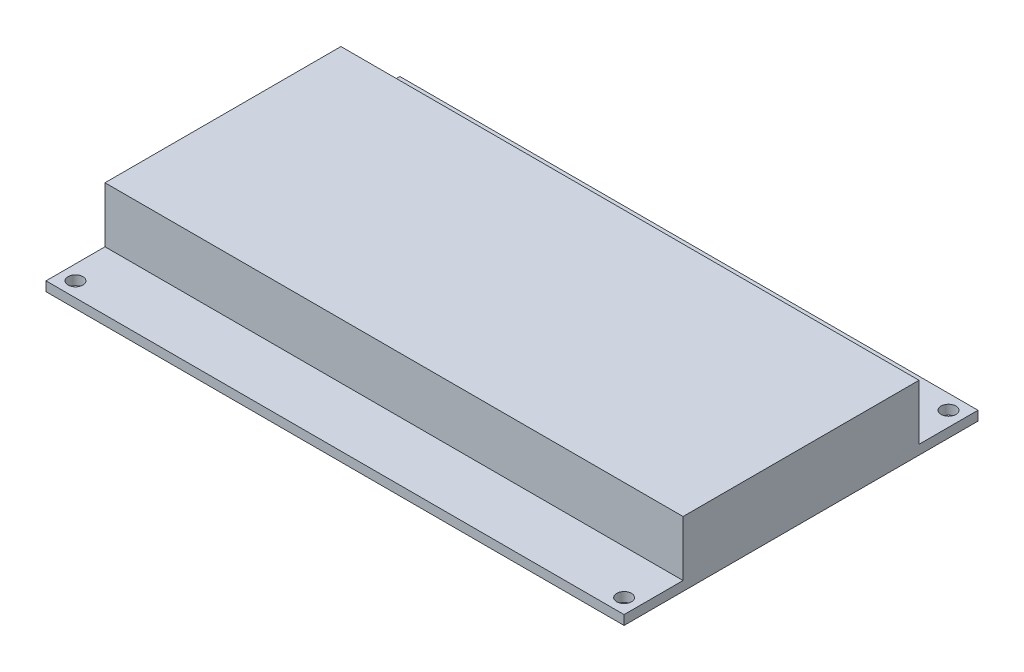
from build123d import *

# Parameters (mm, degrees)
SKETCH_1_W          = 98
SKETCH_1_H          = 60
EXTRUDE_1_DEPTH     = 1.6
SKETCH_1_4_W        = 98
SKETCH_1_4_H        = 40
EXTRUDE_2_DEPTH     = 11
SKETCH_2_W          = 45
SKETCH_2_H          = 25
EXTRUDE_3_DEPTH     = 13
CUT_EXTRUDE_1_REACH = 60.907
SKETCH_3_R          = 1.25


with BuildPart() as part:
    # Эскиз1 → Бобышка-Вытянуть1 (new body)
    with BuildSketch(Plane(origin=(0, 0, 0), x_dir=(1, 0, 0), z_dir=(0, 1, 0))):
        Rectangle(SKETCH_1_W, SKETCH_1_H)
    extrude(amount=EXTRUDE_1_DEPTH)

    # Эскиз1<4> → Бобышка-Вытянуть2 (add)
    with BuildSketch(Plane(origin=(0, 0, 0), x_dir=(1, 0, 0), z_dir=(0, 1, 0))):
        Rectangle(SKETCH_1_4_W, SKETCH_1_4_H)
    extrude(amount=EXTRUDE_2_DEPTH)

    # Эскиз2 → Бобышка-Вытянуть3 (add)
    with BuildSketch(Plane.XZ):
        with Locations((-16.5, -17.5)):
            Rectangle(SKETCH_2_W, SKETCH_2_H)
    extrude(amount=EXTRUDE_3_DEPTH)

    # Эскиз3 → Вырез-Вытянуть1 (cut, up to next)
    with BuildSketch(Plane.XZ, mode=Mode.PRIVATE) as cut_extrude_1_sk1:
        with Locations((46.5, 27.5)):
            Circle(SKETCH_3_R)
    cut_extrude_1_tool1 = extrude(cut_extrude_1_sk1.sketch, amount=-CUT_EXTRUDE_1_REACH, mode=Mode.PRIVATE) & part.part
    # Эскиз3 → Вырез-Вытянуть1 (cut, up to next)
    with BuildSketch(Plane.XZ, mode=Mode.PRIVATE) as cut_extrude_1_sk2:
        with Locations((-46.5, 27.5)):
            Circle(SKETCH_3_R)
    cut_extrude_1_tool2 = extrude(cut_extrude_1_sk2.sketch, amount=-CUT_EXTRUDE_1_REACH, mode=Mode.PRIVATE) & part.part
    # Эскиз3 → Вырез-Вытянуть1 (cut, up to next)
    with BuildSketch(Plane.XZ, mode=Mode.PRIVATE) as cut_extrude_1_sk3:
        with Locations((-46.5, -27.5)):
            Circle(SKETCH_3_R)
    cut_extrude_1_tool3 = extrude(cut_extrude_1_sk3.sketch, amount=-CUT_EXTRUDE_1_REACH, mode=Mode.PRIVATE) & part.part
    # Эскиз3 → Вырез-Вытянуть1 (cut, up to next)
    with BuildSketch(Plane.XZ, mode=Mode.PRIVATE) as cut_extrude_1_sk4:
        with Locations((46.5, -27.5)):
            Circle(SKETCH_3_R)
    cut_extrude_1_tool4 = extrude(cut_extrude_1_sk4.sketch, amount=-CUT_EXTRUDE_1_REACH, mode=Mode.PRIVATE) & part.part
    add(cut_extrude_1_tool1.solids().sort_by_distance((46.5, 0, 27.5))[0], mode=Mode.SUBTRACT)
    add(cut_extrude_1_tool2.solids().sort_by_distance((-46.5, 0, 27.5))[0], mode=Mode.SUBTRACT)
    add(cut_extrude_1_tool3.solids().sort_by_distance((-46.5, 0, -27.5))[0], mode=Mode.SUBTRACT)
    add(cut_extrude_1_tool4.solids().sort_by_distance((46.5, 0, -27.5))[0], mode=Mode.SUBTRACT)


solid = part.part
